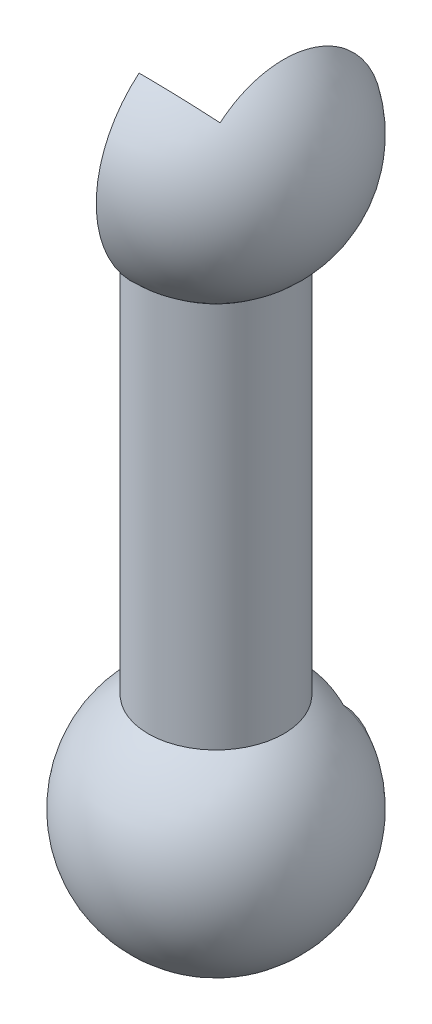
from build123d import *

# Parameters (mm, degrees)
SKETCH_7_R                = 30
SKETCH_7_R_2              = 2
EXTRUDE_1_DEPTH           = 178.35
REVOLVE_1_ANGLE           = 180
SKETCH_13_W               = 62
SKETCH_13_H               = 63.428923534
REVOLVE_2_ANGLE           = 130
REVOLVE_2_OTHER_WAY_ANGLE = 55
SKETCH_15_W               = 45
SKETCH_15_H               = 69.245097843
REVOLVE_6_ANGLE           = 45
REVOLVE_6_OTHER_WAY_ANGLE = 120


with BuildPart() as part:
    # 草图7 → 凸台-拉伸1 (new body)
    with BuildSketch(Plane(origin=(0, 0, 0), x_dir=(1, 0, 0), z_dir=(0, 1, 0))):
        Circle(SKETCH_7_R)
        with Locations((5, 5)):
            Circle(SKETCH_7_R_2, mode=Mode.SUBTRACT)
        with Locations((5, -5)):
            Circle(SKETCH_7_R_2, mode=Mode.SUBTRACT)
        with Locations((-5, -5)):
            Circle(SKETCH_7_R_2, mode=Mode.SUBTRACT)
        with Locations((-5, 5)):
            Circle(SKETCH_7_R_2, mode=Mode.SUBTRACT)
        with BuildLine():
            Line((7.031506006, 8.445719569), (18.371677247, 19.78589081))
            ThreePointArc((18.371677247, 19.78589081), (0, 27), (-18.371677247, 19.78589081))
            Line((-18.371677247, 19.78589081), (-7.031506006, 8.445719569))
            ThreePointArc((-7.031506006, 8.445719569), (-3.469266271, 8.69551813), (-1.127016654, 6))
            Line((-1.127016654, 6), (1.127016654, 6))
            ThreePointArc((1.127016654, 6), (3.469266271, 8.69551813), (7.031506006, 8.445719569))
        make_face(mode=Mode.SUBTRACT)
        with BuildLine():
            Line((8.445719569, 7.031506006), (19.78589081, 18.371677247))
            ThreePointArc((19.78589081, 18.371677247), (27, 0), (19.78589081, -18.371677247))
            Line((19.78589081, -18.371677247), (8.445719569, -7.031506006))
            ThreePointArc((8.445719569, -7.031506006), (8.69551813, -3.469266271), (6, -1.127016654))
            Line((6, -1.127016654), (6, 1.127016654))
            ThreePointArc((6, 1.127016654), (8.69551813, 3.469266271), (8.445719569, 7.031506006))
        make_face(mode=Mode.SUBTRACT)
        with BuildLine():
            Line((7.031506006, -8.445719569), (18.371677247, -19.78589081))
            ThreePointArc((18.371677247, -19.78589081), (0, -27), (-18.371677247, -19.78589081))
            Line((-18.371677247, -19.78589081), (-7.031506006, -8.445719569))
            ThreePointArc((-7.031506006, -8.445719569), (-3.469266271, -8.69551813), (-1.127016654, -6))
            Line((-1.127016654, -6), (1.127016654, -6))
            ThreePointArc((1.127016654, -6), (3.469266271, -8.69551813), (7.031506006, -8.445719569))
        make_face(mode=Mode.SUBTRACT)
        with BuildLine():
            Line((-8.445719569, -7.031506006), (-19.78589081, -18.371677247))
            ThreePointArc((-19.78589081, -18.371677247), (-27, 0), (-19.78589081, 18.371677247))
            Line((-19.78589081, 18.371677247), (-8.445719569, 7.031506006))
            ThreePointArc((-8.445719569, 7.031506006), (-8.69551813, 3.469266271), (-6, 1.127016654))
            Line((-6, 1.127016654), (-6, -1.127016654))
            ThreePointArc((-6, -1.127016654), (-8.69551813, -3.469266271), (-8.445719569, -7.031506006))
        make_face(mode=Mode.SUBTRACT)
        with BuildLine():
            Line((1.127016654, 4), (-1.127016654, 4))
            ThreePointArc((-1.127016654, 4), (-2.171572875, 2.171572875), (-4, 1.127016654))
            Line((-4, 1.127016654), (-4, -1.127016654))
            ThreePointArc((-4, -1.127016654), (-2.171572875, -2.171572875), (-1.127016654, -4))
            Line((-1.127016654, -4), (1.127016654, -4))
            ThreePointArc((1.127016654, -4), (2.171572875, -2.171572875), (4, -1.127016654))
            Line((4, -1.127016654), (4, 1.127016654))
            ThreePointArc((4, 1.127016654), (2.171572875, 2.171572875), (1.127016654, 4))
        make_face(mode=Mode.SUBTRACT)
    extrude(amount=EXTRUDE_1_DEPTH)


with BuildPart() as body_2:
    # 草图8 → 旋转1 (revolve)
    with BuildSketch(Plane(origin=(0, 0, 0), x_dir=(0, 0, -1), z_dir=(1, 0, 0))):
        with BuildLine():
            Line((0, 271.35), (0, 268.35))
            ThreePointArc((0, 268.35), (47.434164903, 234.161388301), (30, 178.35))
            Line((30, 178.35), (30, 174.65789545))
            ThreePointArc((30, 174.65789545), (50.619569048, 234.055388547), (0, 271.35))
        make_face()
    revolve(axis=Axis((0, 218.35, 0), (0, -1, 0)), revolution_arc=REVOLVE_1_ANGLE)


with BuildPart() as body_3:
    # 草图14 → 旋转3 (revolve)
    with BuildSketch(Plane(origin=(0, 0, 0), x_dir=(0, 0, -1), z_dir=(1, 0, 0))):
        with BuildLine():
            Line((30, 3.69210455), (30, 0))
            ThreePointArc((30, 0), (47.434164903, -55.811388301), (0, -90))
            Line((0, -90), (0, -93))
            ThreePointArc((0, -93), (50.619569048, -55.705388547), (30, 3.69210455))
        make_face()
    revolve(axis=Axis((0, 0, 0), (0, -1, 0)))


with BuildPart() as body_4:
    # 草图13 → 旋转2 (revolve)
    with BuildSketch(Plane(origin=(0, 218.35, 0), x_dir=(1, 0, 0), z_dir=(0, 1, 0))):
        with Locations((-1.07172831, 63.714461767)):
            Rectangle(SKETCH_13_W, SKETCH_13_H)
    revolve(axis=Axis((-30.13148335, 218.35, 0), (1, 0, 0)), revolution_arc=REVOLVE_2_ANGLE)

    # 草图13 → 旋转2 other way (revolve)
    with BuildSketch(Plane(origin=(0, 218.35, 0), x_dir=(1, 0, 0), z_dir=(0, 1, 0))):
        with Locations((-1.07172831, 63.714461767)):
            Rectangle(SKETCH_13_W, SKETCH_13_H)
    revolve(axis=Axis((-30.13148335, 218.35, 0), (-1, 0, 0)), revolution_arc=REVOLVE_2_OTHER_WAY_ANGLE)


with BuildPart() as body_5:
    # 草图15 → 旋转6 (revolve)
    with BuildSketch(Plane(origin=(0, -40, 0), x_dir=(1, 0, 0), z_dir=(0, 1, 0))):
        with Locations((0, 34.622548922)):
            Rectangle(SKETCH_15_W, SKETCH_15_H)
    revolve(axis=Axis((-74.394272535, -40, 0), (1, 0, 0)), revolution_arc=REVOLVE_6_ANGLE)

    # 草图15 → 旋转6 other way (revolve)
    with BuildSketch(Plane(origin=(0, -40, 0), x_dir=(1, 0, 0), z_dir=(0, 1, 0))):
        with Locations((0, 34.622548922)):
            Rectangle(SKETCH_15_W, SKETCH_15_H)
    revolve(axis=Axis((-74.394272535, -40, 0), (-1, 0, 0)), revolution_arc=REVOLVE_6_OTHER_WAY_ANGLE)


with BuildPart() as body_2_1:
    add(body_2.part)

    # Combine 1: cut body 4
    add(body_4.part, mode=Mode.SUBTRACT)


with BuildPart() as body_3_1:
    add(body_3.part)

    # Combine 2: cut body 5
    add(body_5.part, mode=Mode.SUBTRACT)


solid = Compound([part.part, body_2_1.part, body_3_1.part])
